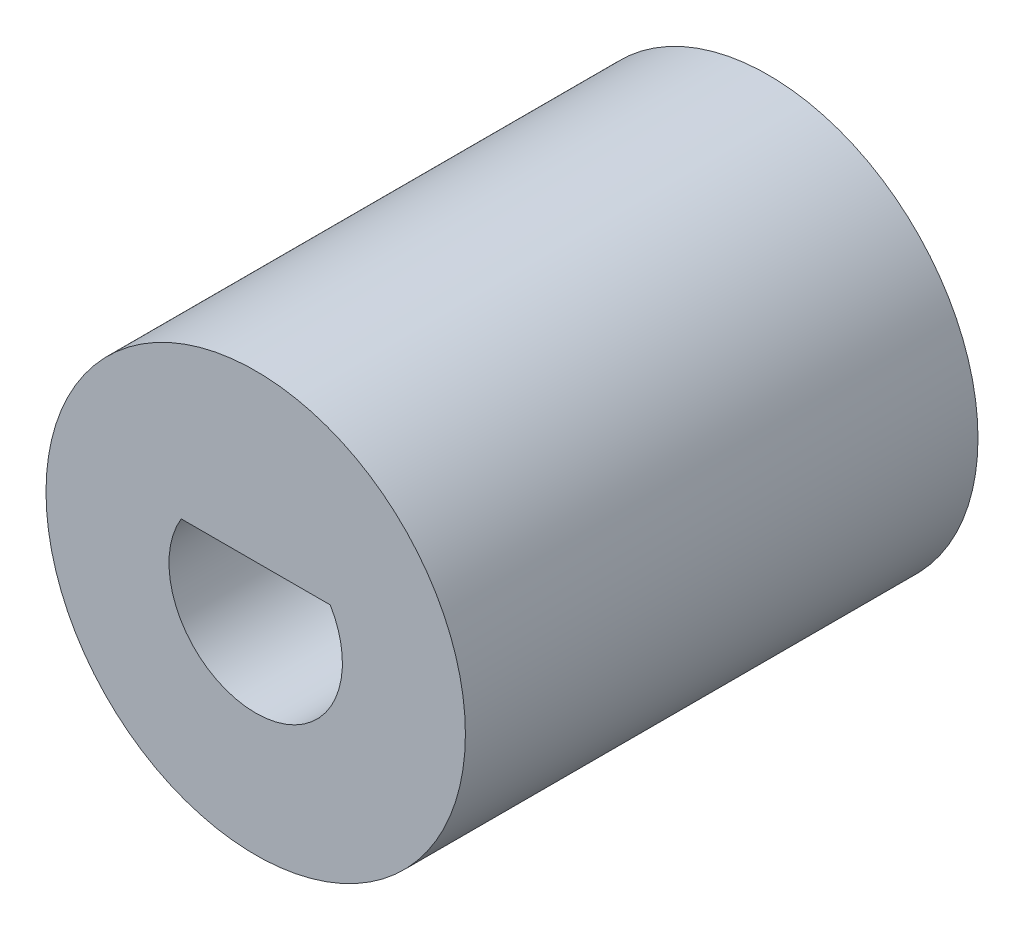
from build123d import *

# Parameters (mm, degrees)
SKETCH1_R           = 4.5
BOSS_EXTRUDE1_DEPTH = 11
CUT_EXTRUDE3_DEPTH  = 2
CUT_EXTRUDE4_DEPTH  = 12


with BuildPart() as part:
    # Sketch1 → Boss-Extrude1 (new body)
    with BuildSketch(Plane.XY):
        with Locations((0, 9.145577701)):
            Circle(SKETCH1_R)
    extrude(amount=BOSS_EXTRUDE1_DEPTH)

    # Sketch6 → Cut-Extrude3 (cut)
    with BuildSketch(Plane(origin=(0, 0, 0), x_dir=(-1, 0, 0), z_dir=(0, 0, -1))):
        Polygon((3.290896534, 9.145577701), (1.645448267, 11.995577701), (-1.645448267, 11.995577701), (-3.290896534, 9.145577701), (-1.645448267, 6.295577701), (1.645448267, 6.295577701), align=None)
    extrude(amount=-CUT_EXTRUDE3_DEPTH, mode=Mode.SUBTRACT)

    # Sketch7 → Cut-Extrude4 (cut, through all)
    with BuildSketch(Plane(origin=(0, 0, 0), x_dir=(-1, 0, 0), z_dir=(0, 0, -1))):
        with BuildLine():
            Line((1.6, 10.095577701), (-1.6, 10.095577701))
            ThreePointArc((-1.6, 10.095577701), (0, 7.284798295), (1.6, 10.095577701))
        make_face()
    extrude(amount=-CUT_EXTRUDE4_DEPTH, mode=Mode.SUBTRACT)


solid = part.part
